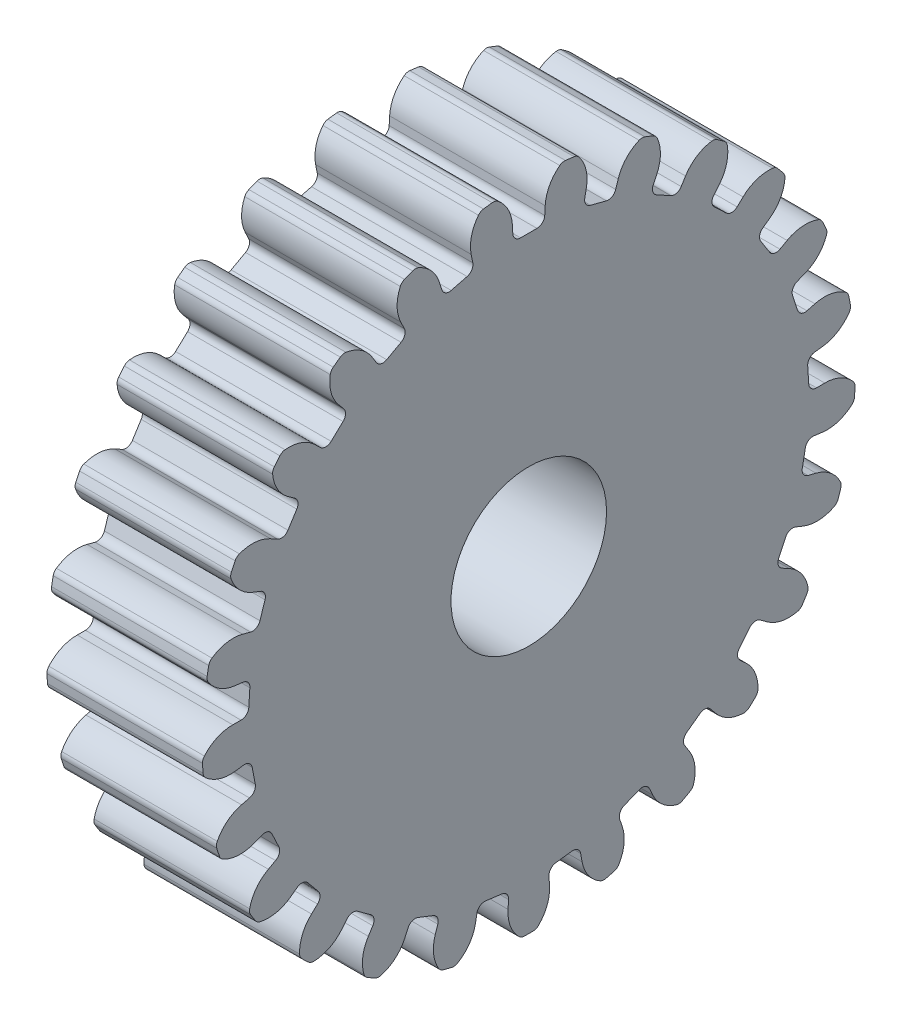
from build123d import *

# Parameters (mm, degrees)
ESQUISSE1_R                        = 10.5
ESQUISSE1_R_2                      = 2.5
EXTRUSION1_DEPTH                   = 5
ENL_V_MAT_EXTRU_2_DEPTH            = 5
CONG_2_R                           = 0.25
R_P_TITION_CIRCULAIRE1_COUNT       = 25
CONG_2_OF_R_P_TITION_CIRCULAIRE1_R = 0.25


with BuildPart() as part:
    # Esquisse1 → Extrusion1 (new body)
    with BuildSketch(Plane(origin=(0, 0, 0), x_dir=(0, 0, -1), z_dir=(1, 0, 0))):
        Circle(ESQUISSE1_R)
        Circle(ESQUISSE1_R_2, mode=Mode.SUBTRACT)
    extrude(amount=EXTRUSION1_DEPTH)

    # Esquisse22 → Enlèv. mat.-Extru.2 (cut)
    with BuildSketch(Plane.ZY):
        with BuildLine():
            Line((-0.5, 9), (0.5, 9))
            Line((0.5, 9), (0.527777778, 9.5))
            ThreePointArc((0.527777778, 9.5), (0.690668814, 10.03926369), (1.082435206, 10.444057355))
            ThreePointArc((1.082435206, 10.444057355), (0, 10.5), (-1.082435206, 10.444057355))
            ThreePointArc((-1.082435206, 10.444057355), (-0.690668814, 10.03926369), (-0.527777778, 9.5))
            Line((-0.527777778, 9.5), (-0.5, 9))
        make_face()
    enl_v_mat_extru_2 = extrude(amount=-ENL_V_MAT_EXTRU_2_DEPTH, mode=Mode.SUBTRACT)

    # Congé2
    cong_2_edges = [part.edges().sort_by_distance(p)[0] for p in [
        (2.5, 9, -0.5),
        (2.5, 10.444057355, -1.082435206),
        (2.5, 10.444057355, 1.082435206),
        (2.5, 9, 0.5),
    ]]
    fillet(cong_2_edges, radius=CONG_2_R)

    # Répétition circulaire1: Enlèv. mat.-Extru.2 ×25 about axis
    r_p_tition_circulaire1_axis = Axis((0, 0, 0), (1, 0, 0))
    for i in range(1, R_P_TITION_CIRCULAIRE1_COUNT):
        add(enl_v_mat_extru_2.rotate(r_p_tition_circulaire1_axis, i * 360 / R_P_TITION_CIRCULAIRE1_COUNT), mode=Mode.SUBTRACT)

    # Congé2 of Répétition circulaire1
    cong_2_of_r_p_tition_circulaire1_edges = [part.edges().sort_by_distance(p)[0] for p in [
        (2.5, 8.841593394, 1.753917404),
        (2.5, 10.385128777, 1.548902931),
        (2.5, 9.846747398, 3.645759959),
        (2.5, 8.592903507, 2.722500565),
        (2.5, 8.127636957, 3.897629727),
        (2.5, 9.673664364, 4.082917801),
        (2.5, 8.630730089, 5.980008205),
        (2.5, 7.645883283, 4.773936407),
        (2.5, 6.9029912, 5.79643964),
        (2.5, 8.354368042, 6.36038793),
        (2.5, 6.872412267, 7.938510543),
        (2.5, 6.218444094, 6.525408267),
        (2.5, 5.244605118, 7.331037932),
        (2.5, 6.510136051, 8.238211493),
        (2.5, 4.682275507, 9.398207067),
        (2.5, 4.400277192, 7.866864727),
        (2.5, 3.256681208, 8.405000149),
        (2.5, 4.256848269, 9.59839793),
        (2.5, 2.197934157, 10.267379678),
        (2.5, 2.305624691, 8.714017144),
        (2.5, 1.06412804, 8.950845296),
        (2.5, 1.736087055, 10.355481724),
        (2.5, -0.42451148, 10.491415062),
        (2.5, 0.066101312, 9.013635816),
        (2.5, -1.195288206, 8.934275914),
        (2.5, -0.893758894, 10.461892517),
        (2.5, -3.020283499, 10.056236253),
        (2.5, -2.177575457, 8.746894599),
        (2.5, -3.379600098, 8.356333118),
        (2.5, -3.467446685, 9.910944127),
        (2.5, -5.426279998, 8.989187137),
        (2.5, -4.28442715, 7.930553826),
        (2.5, -5.351559286, 7.25333118),
        (2.5, -5.823262047, 8.737254668),
        (2.5, -7.491323369, 7.357314332),
        (2.5, -6.122072529, 6.61590719),
        (2.5, -6.987260323, 5.694575768),
        (2.5, -7.813180439, 7.014571364),
        (2.5, -9.085659341, 5.26315441),
        (2.5, -7.575045576, 4.885558773),
        (2.5, -8.183926097, 3.778009217),
        (2.5, -9.312167969, 4.851136744),
        (2.5, -10.109109922, 2.83829114),
        (2.5, -8.552050649, 2.848232731),
        (2.5, -8.866365695, 1.624056453),
        (2.5, -10.226037738, 2.382887361),
        (2.5, -10.497367947, 0.235087599),
        (2.5, -8.991698929, 0.631941751),
        (2.5, -8.991698929, -0.631941751),
        (2.5, -10.497367947, -0.235087599),
        (2.5, -10.226037738, -2.382887361),
        (2.5, -8.866365695, -1.624056453),
        (2.5, -8.552050649, -2.848232731),
        (2.5, -10.109109922, -2.83829114),
        (2.5, -9.312167969, -4.851136744),
        (2.5, -8.183926097, -3.778009217),
        (2.5, -7.575045576, -4.885558773),
        (2.5, -9.085659341, -5.26315441),
        (2.5, -7.813180439, -7.014571364),
        (2.5, -6.987260323, -5.694575768),
        (2.5, -6.122072529, -6.61590719),
        (2.5, -7.491323369, -7.357314332),
        (2.5, -5.823262047, -8.737254668),
        (2.5, -5.351559286, -7.25333118),
        (2.5, -4.28442715, -7.930553826),
        (2.5, -5.426279998, -8.989187137),
        (2.5, -3.467446685, -9.910944127),
        (2.5, -3.379600098, -8.356333118),
        (2.5, -2.177575457, -8.746894599),
        (2.5, -3.020283499, -10.056236253),
        (2.5, -0.893758894, -10.461892517),
        (2.5, -1.195288206, -8.934275914),
        (2.5, 0.066101312, -9.013635816),
        (2.5, -0.42451148, -10.491415062),
        (2.5, 1.736087055, -10.355481724),
        (2.5, 1.06412804, -8.950845296),
        (2.5, 2.305624691, -8.714017144),
        (2.5, 2.197934157, -10.267379678),
        (2.5, 4.256848269, -9.59839793),
        (2.5, 3.256681208, -8.405000149),
        (2.5, 4.400277192, -7.866864727),
        (2.5, 4.682275507, -9.398207067),
        (2.5, 6.510136051, -8.238211493),
        (2.5, 5.244605118, -7.331037932),
        (2.5, 6.218444094, -6.525408267),
        (2.5, 6.872412267, -7.938510543),
        (2.5, 8.354368042, -6.36038793),
        (2.5, 6.9029912, -5.79643964),
        (2.5, 7.645883283, -4.773936407),
        (2.5, 8.630730089, -5.980008205),
        (2.5, 9.673664364, -4.082917801),
        (2.5, 8.127636957, -3.897629727),
        (2.5, 8.592903507, -2.722500565),
        (2.5, 9.846747398, -3.645759959),
        (2.5, 10.385128777, -1.548902931),
        (2.5, 8.841593394, -1.753917404),
    ]]
    fillet(cong_2_of_r_p_tition_circulaire1_edges, radius=CONG_2_OF_R_P_TITION_CIRCULAIRE1_R)


solid = part.part
